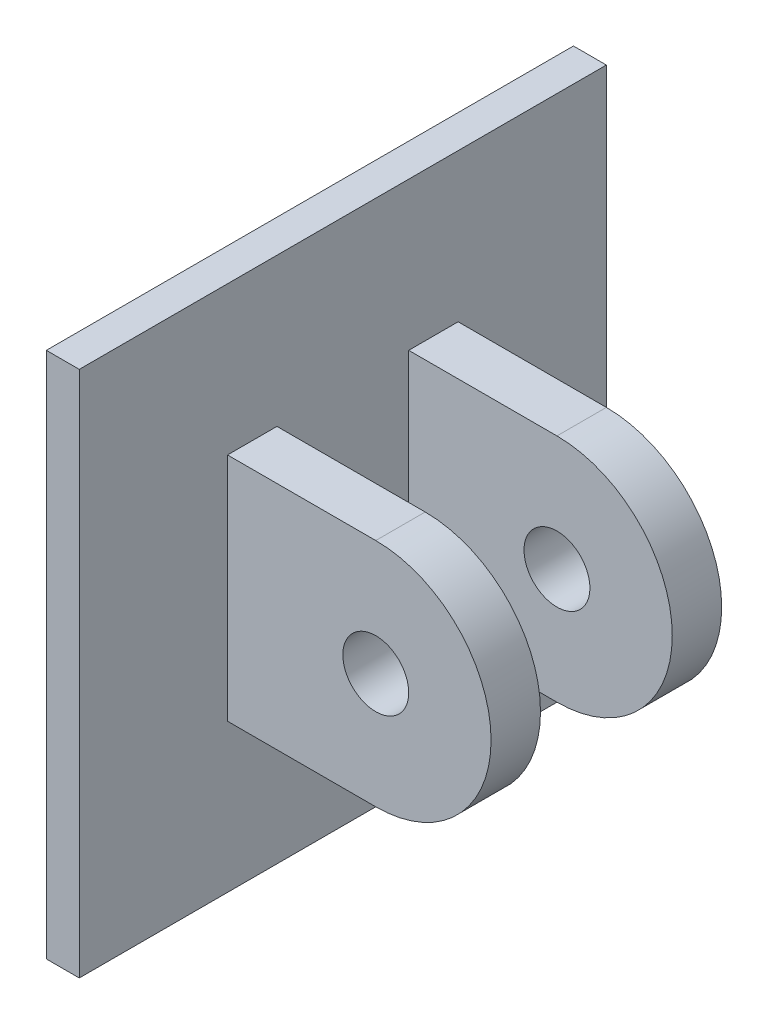
from build123d import *

# Parameters (mm, degrees)
SKETCH1_W           = 101.6
SKETCH1_H           = 101.6
BOSS_EXTRUDE1_DEPTH = 6.35
SKETCH2_W           = 44.45
SKETCH2_H           = 9.525
BOSS_EXTRUDE2_DEPTH = 50.8
SKETCH3_R           = 6.35
CUT_EXTRUDE1_DEPTH  = 106.732743864


with BuildPart() as part:
    # Sketch1 → Boss-Extrude1 (new body)
    with BuildSketch(Plane(origin=(0, 0, 0), x_dir=(0, -1, 0), z_dir=(1, 0, 0))):
        Rectangle(SKETCH1_W, SKETCH1_H)
    extrude(amount=BOSS_EXTRUDE1_DEPTH)

    # Sketch2 → Boss-Extrude2 (add)
    with BuildSketch(Plane(origin=(6.35, 0, 0), x_dir=(0, -1, 0), z_dir=(1, 0, 0))):
        with Locations((0, 17.4625)):
            Rectangle(SKETCH2_W, SKETCH2_H)
        with Locations((0, -17.4625)):
            Rectangle(SKETCH2_W, SKETCH2_H)
    extrude(amount=BOSS_EXTRUDE2_DEPTH)

    # Sketch3 → Cut-Extrude1 (cut, through all)
    with BuildSketch(Plane.YX.offset(22.225)):
        with BuildLine():
            Line((-22.225, 57.15), (-22.225, 34.925))
            ThreePointArc((-22.225, 34.925), (-15.715448108, 50.640448315), (2.93e-07, 57.15))
            Line((2.93e-07, 57.15), (-22.225, 57.15))
        make_face()
        with BuildLine():
            ThreePointArc((2.93e-07, 57.15), (15.715448315, 50.640448108), (22.225, 34.925))
            Line((22.225, 34.925), (22.225, 57.15))
            Line((22.225, 57.15), (2.93e-07, 57.15))
        make_face()
        with Locations((0, 34.925)):
            Circle(SKETCH3_R)
    extrude(amount=-CUT_EXTRUDE1_DEPTH, mode=Mode.SUBTRACT)


solid = part.part
